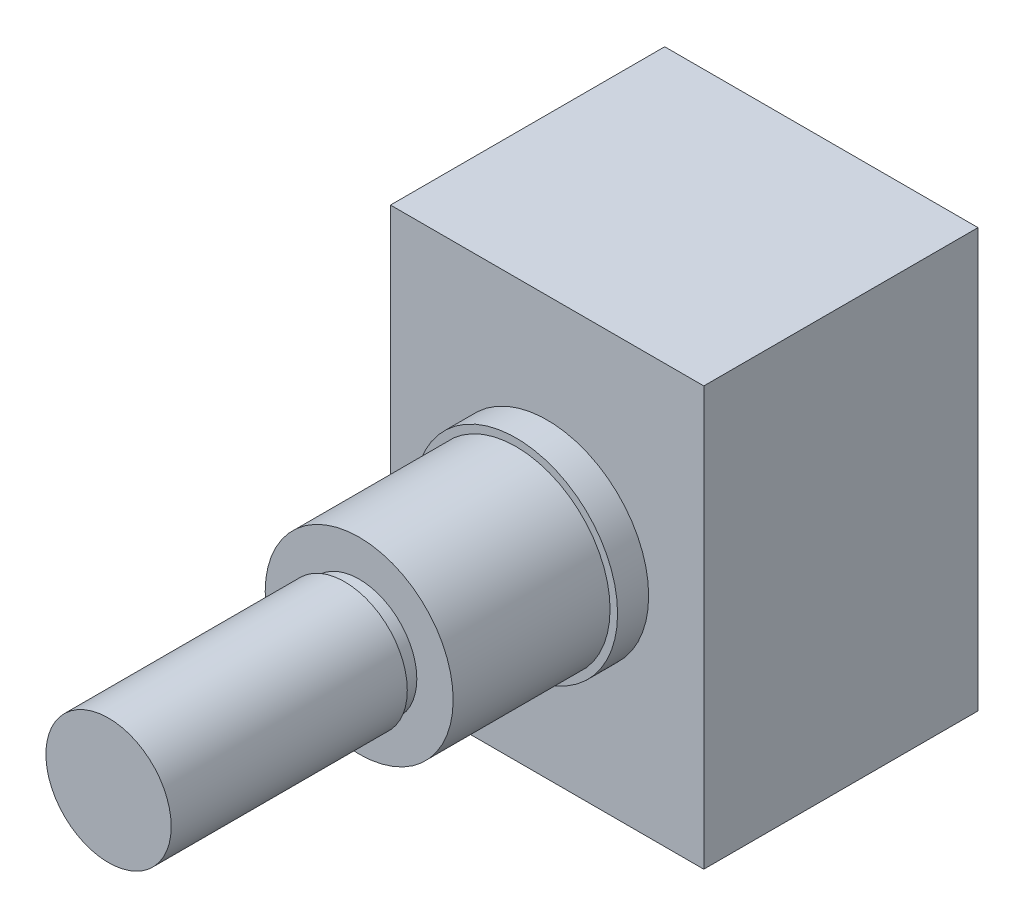
from build123d import *

# Parameters (mm, degrees)
SKETCH1_W           = 15.875
SKETCH1_H           = 21.209
BOSS_EXTRUDE1_DEPTH = 13.8938
SKETCH2_R           = 5.1435
BOSS_EXTRUDE2_DEPTH = 1.5748
SKETCH3_R           = 4.7625
BOSS_EXTRUDE3_DEPTH = 9.525
SKETCH4_R           = 3.175
BOSS_EXTRUDE4_DEPTH = 22.225
SKETCH5_W           = 0.254
SKETCH5_H           = 0.7366


with BuildPart() as part:
    # Sketch1 → Boss-Extrude1 (new body)
    with BuildSketch(Plane.XY):
        Rectangle(SKETCH1_W, SKETCH1_H)
    extrude(amount=BOSS_EXTRUDE1_DEPTH)

    # Sketch2 → Boss-Extrude2 (add)
    with BuildSketch(Plane.XY.offset(13.8938)):
        Circle(SKETCH2_R)
    extrude(amount=BOSS_EXTRUDE2_DEPTH)

    # Sketch3 → Boss-Extrude3 (add)
    with BuildSketch(Plane.XY.offset(13.8938)):
        Circle(SKETCH3_R)
    extrude(amount=BOSS_EXTRUDE3_DEPTH)

    # Sketch4 → Boss-Extrude4 (add)
    with BuildSketch(Plane.XY.offset(13.8938)):
        Circle(SKETCH4_R)
    extrude(amount=BOSS_EXTRUDE4_DEPTH)

    # Sketch5 → Cut-Revolve1 (revolve, cut)
    with BuildSketch(Plane(origin=(0, 0, 0), x_dir=(1, 0, 0), z_dir=(0, 1, 0))):
        with Locations((3.048, -23.7871)):
            Rectangle(SKETCH5_W, SKETCH5_H)
    revolve(axis=Axis((0, 0, 36.1188), (0, 0, -1)), mode=Mode.SUBTRACT)


solid = part.part
